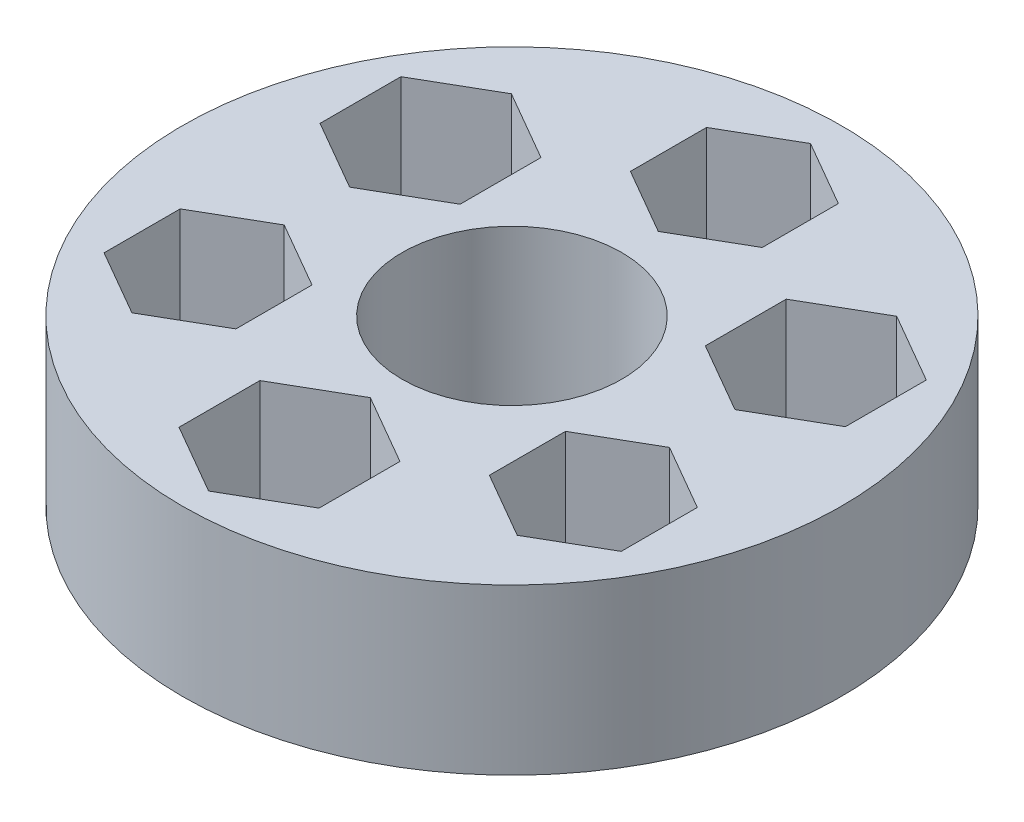
from build123d import *

# Parameters (mm, degrees)
CROQUIS1_R              = 20
SALIENTE_EXTRUIR1_DEPTH = 10
CORTAR_EXTRUIR1_DEPTH   = 10
CROQUIS3_R              = 6.665733382
CORTAR_EXTRUIR2_DEPTH   = 10
CORTAR_EXTRUIR3_DEPTH   = 10


with BuildPart() as part:
    # Croquis1 → Saliente-Extruir1 (new body)
    with BuildSketch(Plane(origin=(0, 0, 0), x_dir=(1, 0, 0), z_dir=(0, 1, 0))):
        Circle(CROQUIS1_R)
    extrude(amount=SALIENTE_EXTRUIR1_DEPTH)

    # Croquis2 → Cortar-Extruir1 (cut)
    with BuildSketch(Plane(origin=(0, 10, 0), x_dir=(1, 0, 0), z_dir=(0, 1, 0))):
        Polygon((7.691342951, -4.440598923), (7.691342951, -9.059401077), (11.691342951, -11.368802154), (15.691342951, -9.059401077), (15.691342951, -4.440598923), (11.691342951, -2.131197846), align=None)
        Polygon((0, 8.881197846), (4, 11.190598923), (4, 15.809401077), (0, 18.118802154), (-4, 15.809401077), (-4, 11.190598923), align=None)
        Polygon((-7.691342951, -4.440598923), (-11.691342951, -2.131197846), (-15.691342951, -4.440598923), (-15.691342951, -9.059401077), (-11.691342951, -11.368802154), (-7.691342951, -9.059401077), align=None)
    extrude(amount=-CORTAR_EXTRUIR1_DEPTH, mode=Mode.SUBTRACT)

    # Croquis3 → Cortar-Extruir2 (cut)
    with BuildSketch(Plane(origin=(0, 10, 0), x_dir=(1, 0, 0), z_dir=(0, 1, 0))):
        Circle(CROQUIS3_R)
    extrude(amount=-CORTAR_EXTRUIR2_DEPTH, mode=Mode.SUBTRACT)

    # Croquis4 → Cortar-Extruir3 (cut)
    with BuildSketch(Plane(origin=(0, 10, 0), x_dir=(1, 0, 0), z_dir=(0, 1, 0))):
        Polygon((-11.691342951, 11.657477288), (-15.941342951, 9.203738644), (-15.941342951, 4.296261356), (-11.691342951, 1.842522712), (-7.441342951, 4.296261356), (-7.441342951, 9.203738644), align=None)
        Polygon((0, -18.407477288), (4.25, -15.953738644), (4.25, -11.046261356), (0, -8.592522712), (-4.25, -11.046261356), (-4.25, -15.953738644), align=None)
        Polygon((15.941342951, 4.296261356), (15.941342951, 9.203738644), (11.691342951, 11.657477288), (7.441342951, 9.203738644), (7.441342951, 4.296261356), (11.691342951, 1.842522712), align=None)
    extrude(amount=-CORTAR_EXTRUIR3_DEPTH, mode=Mode.SUBTRACT)


solid = part.part
